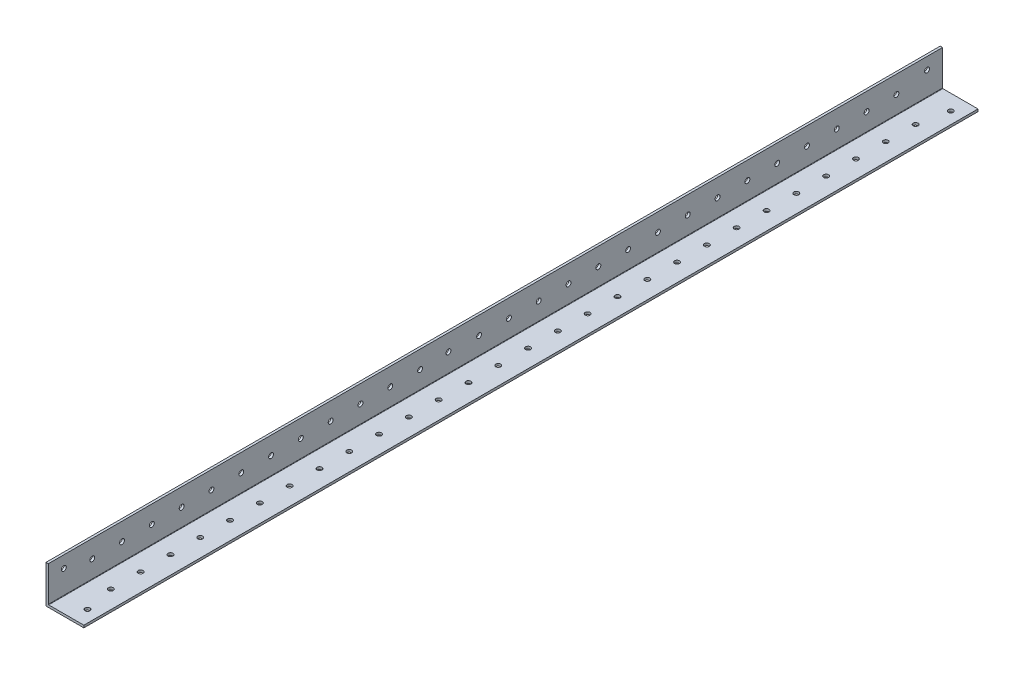
from build123d import *

# Parameters (mm, degrees)
BOSS_EXTRUDE1_DEPTH = 1219.2
FILLET1_R           = 0.254
SKETCH4_W           = 1838.4
SKETCH4_H           = 74.945320812
CUT_EXTRUDE1_DEPTH  = 60
SKETCH5_R           = 1.65
CUT_EXTRUDE2_DEPTH  = 10
SKETCH9_R           = 1.65
CUT_EXTRUDE6_DEPTH  = 60


with BuildPart() as part:
    # Sketch3 → Boss-Extrude1 (new, symmetric)
    with BuildSketch(Plane.XY):
        Polygon((1.5875, 25.4), (0, 25.4), (0, 0), (25.4, 0), (25.4, 1.5875), (1.5875, 1.5875), align=None)
    extrude(amount=BOSS_EXTRUDE1_DEPTH, both=True)

    # Fillet1
    fillet1_edges = [part.edges().sort_by_distance(p)[0] for p in [
        (1.5875, 1.5875, 0),
    ]]
    fillet(fillet1_edges, radius=FILLET1_R)

    # Sketch4 → Cut-Extrude1 (cut)
    with BuildSketch(Plane.ZY):
        with Locations((-300, 37.472660406)):
            Rectangle(SKETCH4_W, SKETCH4_H)
    extrude(amount=-CUT_EXTRUDE1_DEPTH, mode=Mode.SUBTRACT)

    # Sketch5 → Cut-Extrude2 (cut)
    with BuildSketch(Plane(origin=(0, 1.5875, 0), x_dir=(1, 0, 0), z_dir=(0, 1, 0))):
        with Locations(Location((17.4625, -629.5759, 0), (0, 0, 180))):
            Circle(SKETCH5_R)
        with Locations(Location((17.4625, -1208.8241, 0), (0, 0, 180))):
            Circle(SKETCH5_R)
        with Locations(Location((13.49375, -1189.2, 0), (0, 0, 180))):
            Circle(SKETCH5_R)
        with Locations(Location((13.49375, -1169.2, 0), (0, 0, 180))):
            Circle(SKETCH5_R)
        with Locations(Location((13.49375, -1149.2, 0), (0, 0, 180))):
            Circle(SKETCH5_R)
        with Locations(Location((13.49375, -1129.2, 0), (0, 0, 180))):
            Circle(SKETCH5_R)
        with Locations(Location((13.49375, -1109.2, 0), (0, 0, 180))):
            Circle(SKETCH5_R)
        with Locations(Location((13.49375, -1089.2, 0), (0, 0, 180))):
            Circle(SKETCH5_R)
        with Locations(Location((13.49375, -1069.2, 0), (0, 0, 180))):
            Circle(SKETCH5_R)
        with Locations(Location((13.49375, -1049.2, 0), (0, 0, 180))):
            Circle(SKETCH5_R)
        with Locations(Location((13.49375, -1029.2, 0), (0, 0, 180))):
            Circle(SKETCH5_R)
        with Locations(Location((13.49375, -1009.2, 0), (0, 0, 180))):
            Circle(SKETCH5_R)
        with Locations(Location((13.49375, -989.2, 0), (0, 0, 180))):
            Circle(SKETCH5_R)
        with Locations(Location((13.49375, -969.2, 0), (0, 0, 180))):
            Circle(SKETCH5_R)
        with Locations(Location((13.49375, -949.2, 0), (0, 0, 180))):
            Circle(SKETCH5_R)
        with Locations(Location((13.49375, -929.2, 0), (0, 0, 180))):
            Circle(SKETCH5_R)
        with Locations(Location((13.49375, -909.2, 0), (0, 0, 180))):
            Circle(SKETCH5_R)
        with Locations(Location((13.49375, -889.2, 0), (0, 0, 180))):
            Circle(SKETCH5_R)
        with Locations(Location((13.49375, -869.2, 0), (0, 0, 180))):
            Circle(SKETCH5_R)
        with Locations(Location((13.49375, -849.2, 0), (0, 0, 180))):
            Circle(SKETCH5_R)
        with Locations(Location((13.49375, -829.2, 0), (0, 0, 180))):
            Circle(SKETCH5_R)
        with Locations(Location((13.49375, -809.2, 0), (0, 0, 180))):
            Circle(SKETCH5_R)
        with Locations(Location((13.49375, -789.2, 0), (0, 0, 180))):
            Circle(SKETCH5_R)
        with Locations(Location((13.49375, -769.2, 0), (0, 0, 180))):
            Circle(SKETCH5_R)
        with Locations(Location((13.49375, -749.2, 0), (0, 0, 180))):
            Circle(SKETCH5_R)
        with Locations(Location((13.49375, -729.2, 0), (0, 0, 180))):
            Circle(SKETCH5_R)
        with Locations(Location((13.49375, -709.2, 0), (0, 0, 180))):
            Circle(SKETCH5_R)
        with Locations(Location((13.49375, -689.2, 0), (0, 0, 180))):
            Circle(SKETCH5_R)
        with Locations(Location((13.49375, -669.2, 0), (0, 0, 180))):
            Circle(SKETCH5_R)
        with Locations(Location((13.49375, -649.2, 0), (0, 0, 180))):
            Circle(SKETCH5_R)
    extrude(amount=-CUT_EXTRUDE2_DEPTH, mode=Mode.SUBTRACT)

    # Sketch9 → Cut-Extrude6 (cut)
    with BuildSketch(Plane(origin=(1.5875, 0, 0), x_dir=(0, 0, -1), z_dir=(1, 0, 0))):
        with Locations((-629.5759, 17.4625)):
            Circle(SKETCH9_R)
        with Locations((-1208.8241, 17.4625)):
            Circle(SKETCH9_R)
        with Locations((-950.70625, 14.2875)):
            Circle(SKETCH9_R)
        with Locations((-1189.765175, 13.49375)):
            Circle(SKETCH9_R)
        with Locations((-1169.765175, 13.49375)):
            Circle(SKETCH9_R)
        with Locations((-1149.765175, 13.49375)):
            Circle(SKETCH9_R)
        with Locations((-1129.765175, 13.49375)):
            Circle(SKETCH9_R)
        with Locations((-1109.765175, 13.49375)):
            Circle(SKETCH9_R)
        with Locations((-1089.765175, 13.49375)):
            Circle(SKETCH9_R)
        with Locations((-1069.765175, 13.49375)):
            Circle(SKETCH9_R)
        with Locations((-1049.765175, 13.49375)):
            Circle(SKETCH9_R)
        with Locations((-1029.765175, 13.49375)):
            Circle(SKETCH9_R)
        with Locations((-1009.765175, 13.49375)):
            Circle(SKETCH9_R)
        with Locations((-989.765175, 13.49375)):
            Circle(SKETCH9_R)
        with Locations((-969.765175, 13.49375)):
            Circle(SKETCH9_R)
        with Locations((-930.141075, 13.49375)):
            Circle(SKETCH9_R)
        with Locations((-910.141075, 13.49375)):
            Circle(SKETCH9_R)
        with Locations((-890.141075, 13.49375)):
            Circle(SKETCH9_R)
        with Locations((-870.141075, 13.49375)):
            Circle(SKETCH9_R)
        with Locations((-850.141075, 13.49375)):
            Circle(SKETCH9_R)
        with Locations((-830.141075, 13.49375)):
            Circle(SKETCH9_R)
        with Locations((-810.141075, 13.49375)):
            Circle(SKETCH9_R)
        with Locations((-790.141075, 13.49375)):
            Circle(SKETCH9_R)
        with Locations((-770.141075, 13.49375)):
            Circle(SKETCH9_R)
        with Locations((-750.141075, 13.49375)):
            Circle(SKETCH9_R)
        with Locations((-730.141075, 13.49375)):
            Circle(SKETCH9_R)
        with Locations((-710.141075, 13.49375)):
            Circle(SKETCH9_R)
        with Locations((-690.141075, 13.49375)):
            Circle(SKETCH9_R)
        with Locations((-670.141075, 13.49375)):
            Circle(SKETCH9_R)
        with Locations((-650.141075, 13.49375)):
            Circle(SKETCH9_R)
    extrude(amount=-CUT_EXTRUDE6_DEPTH, mode=Mode.SUBTRACT)


solid = part.part
